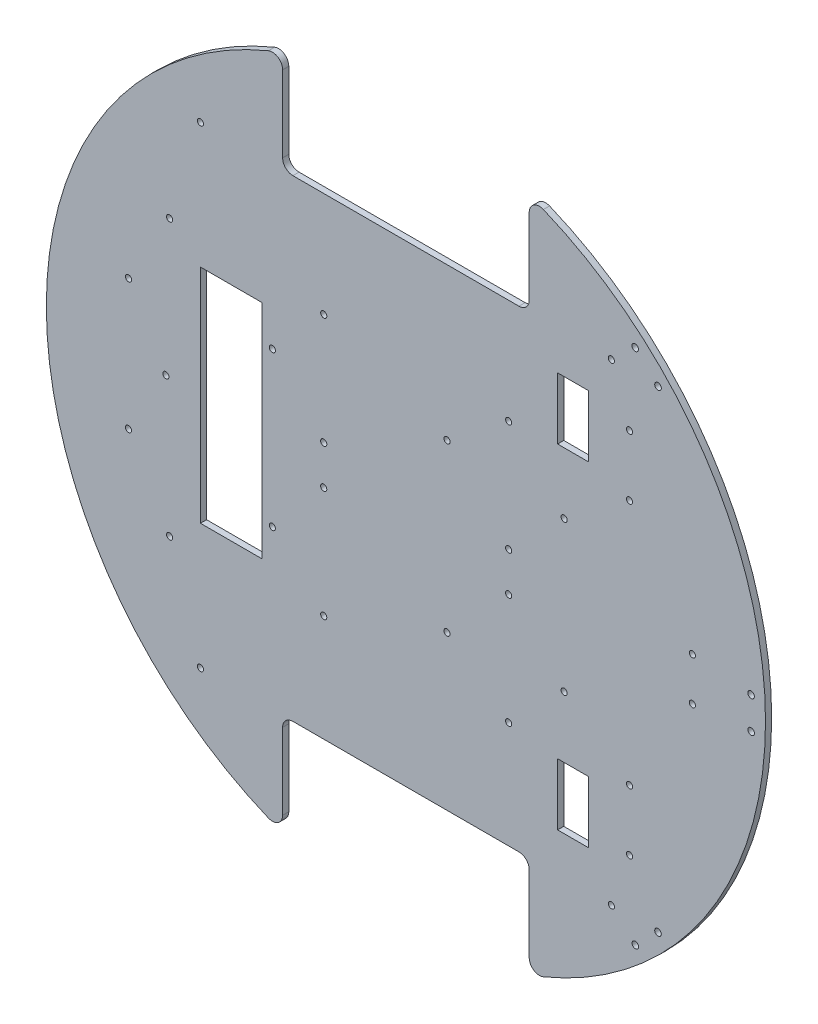
from build123d import *

# Parameters (mm, degrees)
SKETCH_1_R             = 175
EXTRUDE_1_DEPTH        = 3
CUT_EXTRUDE_1_DEPTH    = 3
FILLET_1_R             = 5
FILLET_2_R             = 5
FILLET_3_R             = 5
SKETCH_5_R             = 1.5
CUT_EXTRUDE_4_DEPTH    = 3
SKETCH_7_W             = 30
SKETCH_7_H             = 108
CUT_EXTRUDE_6_DEPTH    = 3
SKETCH_8_R             = 1.5
CUT_EXTRUDE_7_DEPTH    = 3
SKETCH_9_R             = 1.5
CUT_EXTRUDE_8_DEPTH    = 10
SKETCH_10_R            = 1.6
CUT_EXTRUDE_9_DEPTH    = 3
SKETCH_11_W            = 15
SKETCH_11_H            = 30
CUT_EXTRUDE_10_DEPTH   = 10
SKETCH_12_R            = 1.5
CUT_EXTRUDE_11_DEPTH   = 4
SKETCH_13_R            = 1.5
CUT_EXTRUDE_12_DEPTH   = 4
PATTERN_LINEAR_1_COUNT = 2
PATTERN_LINEAR_1_PITCH = 73
SKETCH_14_R            = 1.5
CUT_EXTRUDE_14_DEPTH   = 4
SKETCH_17_R            = 1.5
CUT_EXTRUDE_15_DEPTH   = 4
SKETCH_18_R            = 1.5
CUT_EXTRUDE_16_DEPTH   = 4


with BuildPart() as part:
    # ｽｹｯﾁ1 → ﾎﾞｽ - 押し出し1 (new body)
    with BuildSketch(Plane.XY):
        Circle(SKETCH_1_R)
    extrude(amount=EXTRUDE_1_DEPTH)

    # ｽｹｯﾁ2 → ｶｯﾄ - 押し出し1 (cut)
    with BuildSketch(Plane.XY.offset(3)):
        with BuildLine():
            Line((-60, 115), (0, 115))
            Line((0, 115), (0, 175))
            ThreePointArc((0, 175), (-30.465194158, 172.327803749), (-60, 164.392822228))
            Line((-60, 164.392822228), (-60, 115))
        make_face()
        with BuildLine():
            Line((0, 175), (0, 115))
            Line((0, 115), (60, 115))
            Line((60, 115), (60, 164.392822228))
            ThreePointArc((60, 164.392822228), (30.465194158, 172.327803749), (0, 175))
        make_face()
        with BuildLine():
            Line((0, -175), (0, -115))
            Line((0, -115), (-60, -115))
            Line((-60, -115), (-60, -164.392822228))
            ThreePointArc((-60, -164.392822228), (-30.465194158, -172.327803749), (0, -175))
        make_face()
        with BuildLine():
            Line((60, -115), (0, -115))
            Line((0, -115), (0, -175))
            ThreePointArc((0, -175), (30.465194158, -172.327803749), (60, -164.392822228))
            Line((60, -164.392822228), (60, -115))
        make_face()
    extrude(amount=-CUT_EXTRUDE_1_DEPTH, mode=Mode.SUBTRACT)

    # ﾌｨﾚｯﾄ1
    fillet_1_edges = [part.edges().sort_by_distance(p)[0] for p in [
        (-60, 164.392822228, 1.5),
    ]]
    fillet(fillet_1_edges, radius=FILLET_1_R)

    # ﾌｨﾚｯﾄ2
    fillet_2_edges = [part.edges().sort_by_distance(p)[0] for p in [
        (-60, 115, 1.5),
        (60, 164.392822228, 1.5),
        (60, 115, 1.5),
    ]]
    fillet(fillet_2_edges, radius=FILLET_2_R)

    # ﾌｨﾚｯﾄ3
    fillet_3_edges = [part.edges().sort_by_distance(p)[0] for p in [
        (-60, -115, 1.5),
        (60, -115, 1.5),
        (60, -164.392822228, 1.5),
        (-60, -164.392822228, 1.5),
    ]]
    fillet(fillet_3_edges, radius=FILLET_3_R)

    # ｽｹｯﾁ5 → ｶｯﾄ - 押し出し4 (cut)
    with BuildSketch(Plane.XY.offset(3)):
        with Locations((-100, -115)):
            Circle(SKETCH_5_R)
        with Locations((100, -115)):
            Circle(SKETCH_5_R)
        with Locations((100, 115)):
            Circle(SKETCH_5_R)
        with Locations((-100, 115)):
            Circle(SKETCH_5_R)
    extrude(amount=-CUT_EXTRUDE_4_DEPTH, mode=Mode.SUBTRACT)

    # ｽｹｯﾁ7 → ｶｯﾄ - 押し出し6 (cut)
    with BuildSketch(Plane.XY.offset(3)):
        with Locations((-85, 0)):
            Rectangle(SKETCH_7_W, SKETCH_7_H)
    extrude(amount=-CUT_EXTRUDE_6_DEPTH, mode=Mode.SUBTRACT)

    # ｽｹｯﾁ8 → ｶｯﾄ - 押し出し7 (cut)
    with BuildSketch(Plane.XY.offset(3)):
        with Locations((-115, -67)):
            Circle(SKETCH_8_R)
        with Locations((-116.822468618, 0)):
            Circle(SKETCH_8_R)
        with Locations((-115, 67)):
            Circle(SKETCH_8_R)
    extrude(amount=-CUT_EXTRUDE_7_DEPTH, mode=Mode.SUBTRACT)

    # ｽｹｯﾁ9 → ｶｯﾄ - 押し出し8 (cut)
    with BuildSketch(Plane.XY.offset(3)):
        with Locations((-65, 37)):
            Circle(SKETCH_9_R)
        with Locations((20, 41)):
            Circle(SKETCH_9_R)
        with Locations((-65, -38)):
            Circle(SKETCH_9_R)
        with Locations((20, -40)):
            Circle(SKETCH_9_R)
    extrude(amount=-CUT_EXTRUDE_8_DEPTH, mode=Mode.SUBTRACT)

    # ｽｹｯﾁ10 → ｶｯﾄ - 押し出し9 (cut)
    with BuildSketch(Plane.XY.offset(3)):
        with Locations((111.643659725, -125.921059639)):
            Circle(SKETCH_10_R)
        with Locations((122.679794489, -115.037952538)):
            Circle(SKETCH_10_R)
        with Locations((168, 7.75)):
            Circle(SKETCH_10_R)
        with Locations((168, -7.75)):
            Circle(SKETCH_10_R)
        with Locations((111.56768007, 125.844011632)):
            Circle(SKETCH_10_R)
        with Locations((122.679794489, 115.037952538)):
            Circle(SKETCH_10_R)
    extrude(amount=-CUT_EXTRUDE_9_DEPTH, mode=Mode.SUBTRACT)

    # ｽｹｯﾁ11 → ｶｯﾄ - 押し出し10 (cut)
    with BuildSketch(Plane.XY.offset(3)):
        with Locations((81.317279836, 81.317279836)):
            Rectangle(SKETCH_11_W, SKETCH_11_H)
        with Locations((81.317279836, -81.317279836)):
            Rectangle(SKETCH_11_W, SKETCH_11_H)
    extrude(amount=-CUT_EXTRUDE_10_DEPTH, mode=Mode.SUBTRACT)

    # ｽｹｯﾁ12 → ｶｯﾄ - 押し出し11 (cut, through all)
    with BuildSketch(Plane.XY.offset(3)):
        with Locations((139.4, 10.5)):
            Circle(SKETCH_12_R)
        with Locations((139.4, -10.5)):
            Circle(SKETCH_12_R)
    extrude(amount=-CUT_EXTRUDE_11_DEPTH, mode=Mode.SUBTRACT)

    # ｽｹｯﾁ13 → ｶｯﾄ - 押し出し12 (cut, through all)
    with BuildSketch(Plane.XY.offset(3)):
        with Locations((50, 10)):
            Circle(SKETCH_13_R)
        with Locations((50, 64)):
            Circle(SKETCH_13_R)
        with Locations((-40, 64)):
            Circle(SKETCH_13_R)
        with Locations((-40, 10)):
            Circle(SKETCH_13_R)
        with Locations((77, 36.5)):
            Circle(SKETCH_13_R)
    cut_extrude_12 = extrude(amount=-CUT_EXTRUDE_12_DEPTH, mode=Mode.SUBTRACT)

    # 直線ﾊﾟﾀｰﾝ1: ｶｯﾄ - 押し出し12 ×2
    with Locations(*[(0, -i * PATTERN_LINEAR_1_PITCH, 0) for i in range(1, PATTERN_LINEAR_1_COUNT)]):
        add(cut_extrude_12, mode=Mode.SUBTRACT)

    # ｽｹｯﾁ14 → ｶｯﾄ - 押し出し14 (cut, through all)
    with BuildSketch(Plane.XY.offset(3)):
        with Locations((108.817279836, 89.5)):
            Circle(SKETCH_14_R)
        with Locations((108.817279836, 60)):
            Circle(SKETCH_14_R)
    extrude(amount=-CUT_EXTRUDE_14_DEPTH, mode=Mode.SUBTRACT)

    # ｽｹｯﾁ17 → ｶｯﾄ - 押し出し15 (cut, through all)
    with BuildSketch(Plane.XY.offset(3)):
        with Locations((108.817279836, -60)):
            Circle(SKETCH_17_R)
        with Locations((108.817279836, -89.5)):
            Circle(SKETCH_17_R)
    extrude(amount=-CUT_EXTRUDE_15_DEPTH, mode=Mode.SUBTRACT)

    # ｽｹｯﾁ18 → ｶｯﾄ - 押し出し16 (cut, through all)
    with BuildSketch(Plane.XY.offset(3)):
        with Locations((-135, 31.75)):
            Circle(SKETCH_18_R)
        with Locations((-135, -31.75)):
            Circle(SKETCH_18_R)
    extrude(amount=-CUT_EXTRUDE_16_DEPTH, mode=Mode.SUBTRACT)


solid = part.part
